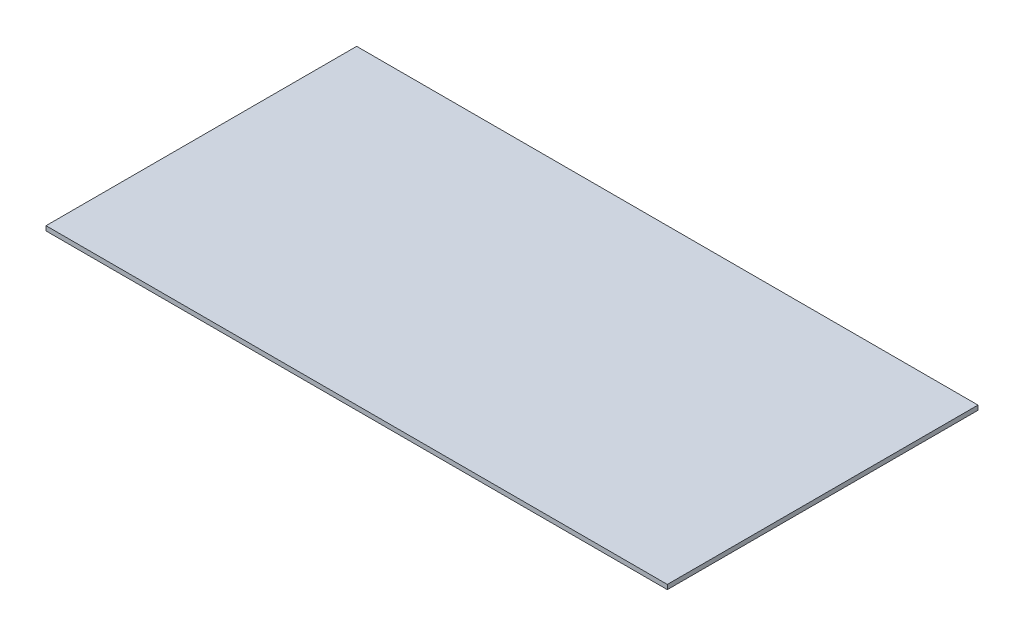
from build123d import *

# Parameters (mm, degrees)
SKETCH2_W                = 2438.4
SKETCH2_H                = 1219.2
BOSS_EXTRUDE1_DEPTH      = 8.9281
BOSS_EXTRUDE1_DEPTH_BACK = 8.9281


with BuildPart() as part:
    # Sketch2 → Boss-Extrude1 (new body, two sides)
    with BuildSketch(Plane(origin=(0, 0, 0), x_dir=(1, 0, 0), z_dir=(0, 1, 0))) as boss_extrude1_sk:
        Rectangle(SKETCH2_W, SKETCH2_H)
    extrude(amount=BOSS_EXTRUDE1_DEPTH)
    extrude(boss_extrude1_sk.sketch, amount=-BOSS_EXTRUDE1_DEPTH_BACK)


solid = part.part
